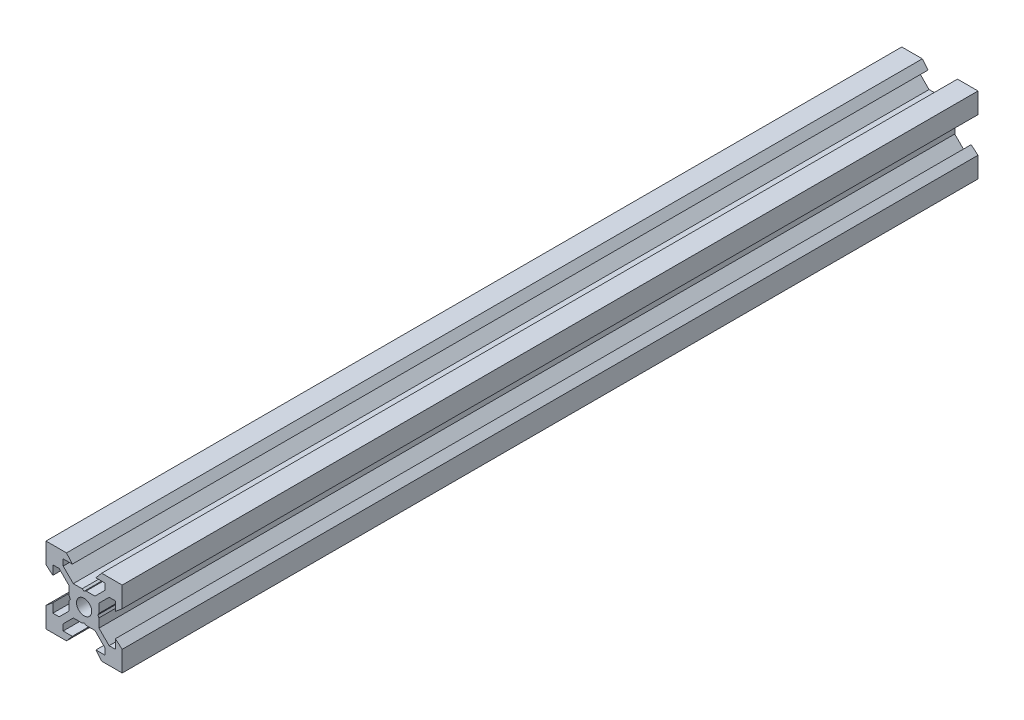
from build123d import *

# Parameters (mm, degrees)
SKETCH1_R           = 2
BOSS_EXTRUDE1_DEPTH = 112.285


with BuildPart() as part:
    # Sketch1 → Boss-Extrude1 (new body, symmetric)
    with BuildSketch(Plane.XY):
        Polygon((10, 10), (10, 4.610379336), (8.2, 3.1), (8.2, 5.5), (6.560660172, 5.5), (3.9, 2.839339828), (3.9, 0.519615242), (3.6, 0), (3.9, -0.519615242), (3.9, -2.839339828), (6.560660172, -5.5), (8.2, -5.5), (8.2, -3.1), (10, -4.610379336), (10, -10), (4.610379336, -10), (3.1, -8.2), (5.5, -8.2), (5.5, -6.560660172), (2.839339828, -3.9), (0.519615242, -3.9), (0, -3.6), (-0.519615242, -3.9), (-2.839339828, -3.9), (-5.5, -6.560660172), (-5.5, -8.2), (-3.1, -8.2), (-4.610379336, -10), (-10, -10), (-10, -4.610379336), (-8.2, -3.1), (-8.2, -5.5), (-6.560660172, -5.5), (-3.9, -2.839339828), (-3.9, -0.519615242), (-3.6, 0), (-3.9, 0.519615242), (-3.9, 2.839339828), (-6.560660172, 5.5), (-8.2, 5.5), (-8.2, 3.1), (-10, 4.610379336), (-10, 10), (-4.610379336, 10), (-3.1, 8.2), (-5.5, 8.2), (-5.5, 6.560660172), (-2.839339828, 3.9), (-0.519615242, 3.9), (0, 3.6), (0.519615242, 3.9), (2.839339828, 3.9), (5.5, 6.560660172), (5.5, 8.2), (3.1, 8.2), (4.610379336, 10), align=None)
        Circle(SKETCH1_R, mode=Mode.SUBTRACT)
    extrude(amount=BOSS_EXTRUDE1_DEPTH, both=True)


solid = part.part
